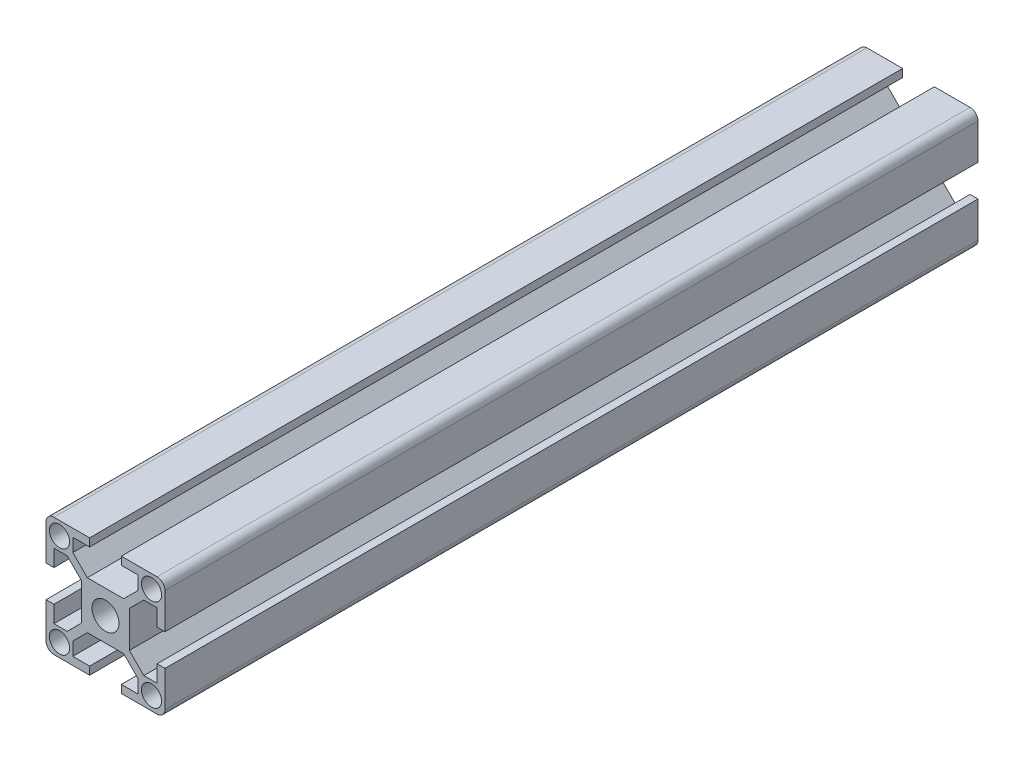
from build123d import *

# Parameters (mm, degrees)
SKETCH1_R           = 2.55
SKETCH1_R_2         = 3.4
BOSS_EXTRUDE1_DEPTH = 205


with BuildPart() as part:
    # Sketch1 → Boss-Extrude1 (new body)
    with BuildSketch(Plane.XY):
        with BuildLine():
            Line((13, 4), (15, 4))
            Line((15, 4), (15, 13))
            ThreePointArc((15, 13), (14.414213562, 14.414213562), (13, 15))
            Line((13, 15), (4, 15))
            Line((4, 15), (4, 13))
            Line((4, 13), (8.25, 13))
            Line((8.25, 13), (8.25, 9.664213562))
            Line((8.25, 9.664213562), (4.585786438, 6))
            Line((4.585786438, 6), (-4.585786438, 6))
            Line((-4.585786438, 6), (-8.25, 9.664213562))
            Line((-8.25, 9.664213562), (-8.25, 13))
            Line((-8.25, 13), (-4, 13))
            Line((-4, 13), (-4, 15))
            Line((-4, 15), (-13, 15))
            ThreePointArc((-13, 15), (-14.414213562, 14.414213562), (-15, 13))
            Line((-15, 13), (-15, 4))
            Line((-15, 4), (-13, 4))
            Line((-13, 4), (-13, 8.25))
            Line((-13, 8.25), (-9.664213562, 8.25))
            Line((-9.664213562, 8.25), (-6, 4.585786438))
            Line((-6, 4.585786438), (-6, -4.585786438))
            Line((-6, -4.585786438), (-9.664213562, -8.25))
            Line((-9.664213562, -8.25), (-13, -8.25))
            Line((-13, -8.25), (-13, -4))
            Line((-13, -4), (-15, -4))
            Line((-15, -4), (-15, -13))
            ThreePointArc((-15, -13), (-14.414213562, -14.414213562), (-13, -15))
            Line((-13, -15), (-4, -15))
            Line((-4, -15), (-4, -13))
            Line((-4, -13), (-8.25, -13))
            Line((-8.25, -13), (-8.25, -9.664213562))
            Line((-8.25, -9.664213562), (-4.585786438, -6))
            Line((-4.585786438, -6), (4.585786438, -6))
            Line((4.585786438, -6), (8.25, -9.664213562))
            Line((8.25, -9.664213562), (8.25, -13))
            Line((8.25, -13), (4, -13))
            Line((4, -13), (4, -15))
            Line((4, -15), (13, -15))
            ThreePointArc((13, -15), (14.414213562, -14.414213562), (15, -13))
            Line((15, -13), (15, -4))
            Line((15, -4), (13, -4))
            Line((13, -4), (13, -8.25))
            Line((13, -8.25), (9.664213562, -8.25))
            Line((9.664213562, -8.25), (6, -4.585786438))
            Line((6, -4.585786438), (6, 4.585786438))
            Line((6, 4.585786438), (9.664213562, 8.25))
            Line((9.664213562, 8.25), (13, 8.25))
            Line((13, 8.25), (13, 4))
        make_face()
        with Locations(Location((-11.6, 11.6, 0), (0, 0, 180))):  # turned: the seam where the file's is
            Circle(SKETCH1_R, mode=Mode.SUBTRACT)
        with Locations(Location((11.6, -11.6, 0), (0, 0, 180))):  # turned: the seam where the file's is
            Circle(SKETCH1_R, mode=Mode.SUBTRACT)
        with Locations(Location((-11.6, -11.6, 0), (0, 0, 180))):  # turned: the seam where the file's is
            Circle(SKETCH1_R, mode=Mode.SUBTRACT)
        with Locations(Location((11.6, 11.6, 0), (0, 0, 180))):  # turned: the seam where the file's is
            Circle(SKETCH1_R, mode=Mode.SUBTRACT)
        with Locations(Location((0, 0, 0), (0, 0, 180))):  # turned: the seam where the file's is
            Circle(SKETCH1_R_2, mode=Mode.SUBTRACT)
    extrude(amount=BOSS_EXTRUDE1_DEPTH)


solid = part.part
